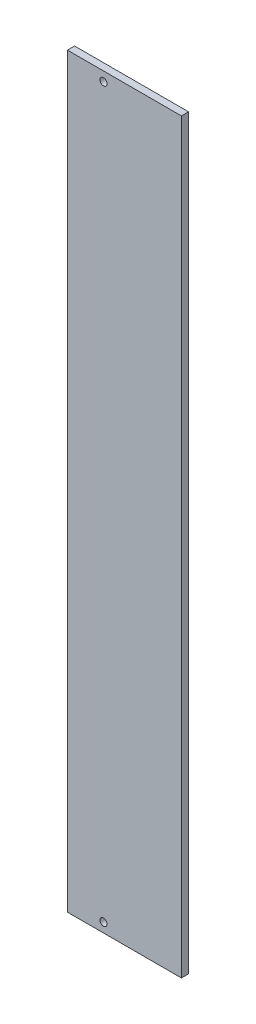
from build123d import *

# Parameters (mm, degrees)
SKETCH1_W           = 40
SKETCH1_H           = 262
SKETCH1_R           = 1.25
BOSS_EXTRUDE1_DEPTH = 2.5


with BuildPart() as part:
    # Sketch1 → Boss-Extrude1 (new body)
    with BuildSketch(Plane.XY):
        with Locations((20, 131)):
            Rectangle(SKETCH1_W, SKETCH1_H)
        with Locations((12.65, 258.7)):
            Circle(SKETCH1_R, mode=Mode.SUBTRACT)
        with Locations((12.65, 3.3)):
            Circle(SKETCH1_R, mode=Mode.SUBTRACT)
    extrude(amount=BOSS_EXTRUDE1_DEPTH)


solid = part.part
